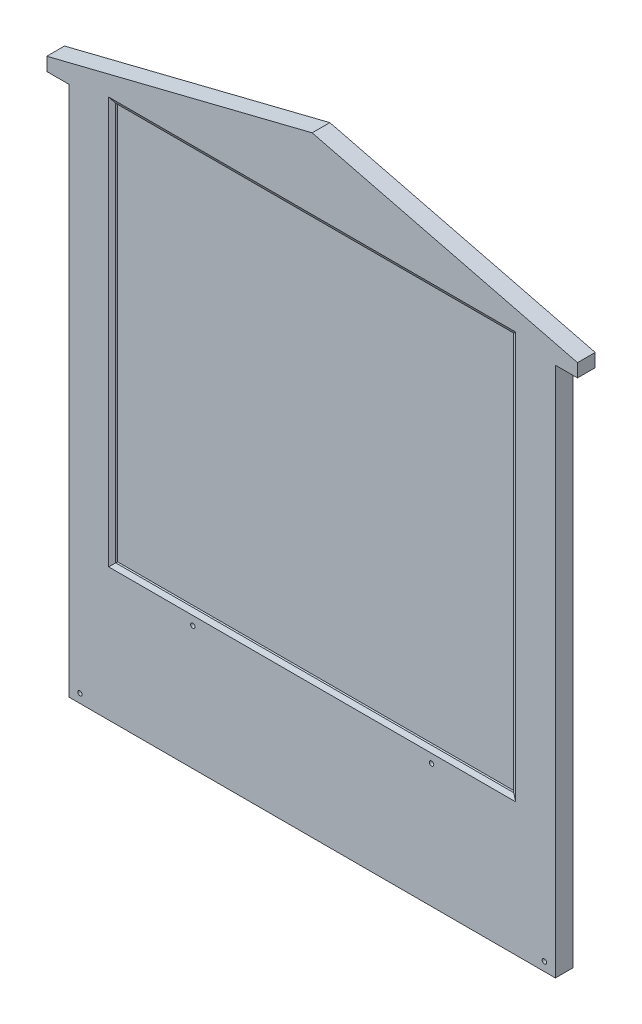
from build123d import *

# Parameters (mm, degrees)
SKETCH_1_W          = 110
SKETCH_1_H          = 4
EXTRUDE_1_DEPTH     = 120
SKETCH_2_W          = 120
SKETCH_2_H          = 4
EXTRUDE_2_DEPTH     = 18
CUT_EXTRUDE_1_DEPTH = 5
SKETCH_4_W          = 90
SKETCH_4_H          = 90
CUT_EXTRUDE_2_DEPTH = 1
SKETCH_6_R          = 0.5
CUT_EXTRUDE_3_DEPTH = 5
SKETCH_7_R          = 1.25
CUT_EXTRUDE_4_DEPTH = 1
CHAMFER_1_SIZE      = 1
CHAMFER_1_SIZE2     = 0.577350269


with BuildPart() as part:
    # 草图1 → 凸台-拉伸1 (new body)
    with BuildSketch(Plane(origin=(0, 0, 0), x_dir=(1, 0, 0), z_dir=(0, 1, 0))):
        Rectangle(SKETCH_1_W, SKETCH_1_H)
    extrude(amount=EXTRUDE_1_DEPTH)

    # 草图2 → 凸台-拉伸2 (add)
    with BuildSketch(Plane(origin=(0, 120, 0), x_dir=(1, 0, 0), z_dir=(0, 1, 0))):
        Rectangle(SKETCH_2_W, SKETCH_2_H)
    extrude(amount=EXTRUDE_2_DEPTH)

    # 草图3 → 切除-拉伸1 (cut, through all)
    with BuildSketch(Plane.XY.offset(2)):
        Polygon((-60, 138), (0, 138), (-60, 123), align=None)
    cut_extrude_1 = extrude(amount=-CUT_EXTRUDE_1_DEPTH, mode=Mode.SUBTRACT)

    # 镜向1: 切除-拉伸1 across plane
    add(cut_extrude_1.mirror(Plane(origin=(0, 0, 0), x_dir=(0, 0, 1), z_dir=(1, 0, 0))), mode=Mode.SUBTRACT)

    # 草图4 → 切除-拉伸2 (cut)
    with BuildSketch(Plane.XY.offset(2)):
        with Locations((0, 76)):
            Rectangle(SKETCH_4_W, SKETCH_4_H)
    extrude(amount=-CUT_EXTRUDE_2_DEPTH, mode=Mode.SUBTRACT)

    # 草图6 → 切除-拉伸3 (cut, through all)
    with BuildSketch(Plane(origin=(0, 0, -2), x_dir=(-1, 0, 0), z_dir=(0, 0, -1))):
        with Locations((-52.5, 2)):
            Circle(SKETCH_6_R)
        with Locations((-27, 28)):
            Circle(SKETCH_6_R)
        with Locations((27, 28)):
            Circle(SKETCH_6_R)
        with Locations((52.5, 2)):
            Circle(SKETCH_6_R)
    extrude(amount=-CUT_EXTRUDE_3_DEPTH, mode=Mode.SUBTRACT)

    # 草图7 → 切除-拉伸4 (cut)
    with BuildSketch(Plane(origin=(0, 0, -2), x_dir=(-1, 0, 0), z_dir=(0, 0, -1))):
        with Locations((-52.5, 2)):
            Circle(SKETCH_7_R)
        with Locations((-27, 28)):
            Circle(SKETCH_7_R)
        with Locations((27, 28)):
            Circle(SKETCH_7_R)
        with Locations((52.5, 2)):
            Circle(SKETCH_7_R)
    extrude(amount=-CUT_EXTRUDE_4_DEPTH, mode=Mode.SUBTRACT)

    # 倒角1
    chamfer_1_edges = [part.edges().sort_by_distance(p)[0] for p in [
        (-45, 76, 2),
        (0, 31, 2),
        (45, 76, 2),
        (0, 121, 2),
    ]]
    chamfer_1_side = [part.faces().sort_by_distance(p)[0] for p in [
        (57.5, 121.828770078, 2),
    ]]
    chamfer(chamfer_1_edges, length=CHAMFER_1_SIZE, length2=CHAMFER_1_SIZE2, reference=chamfer_1_side[0])


solid = part.part
